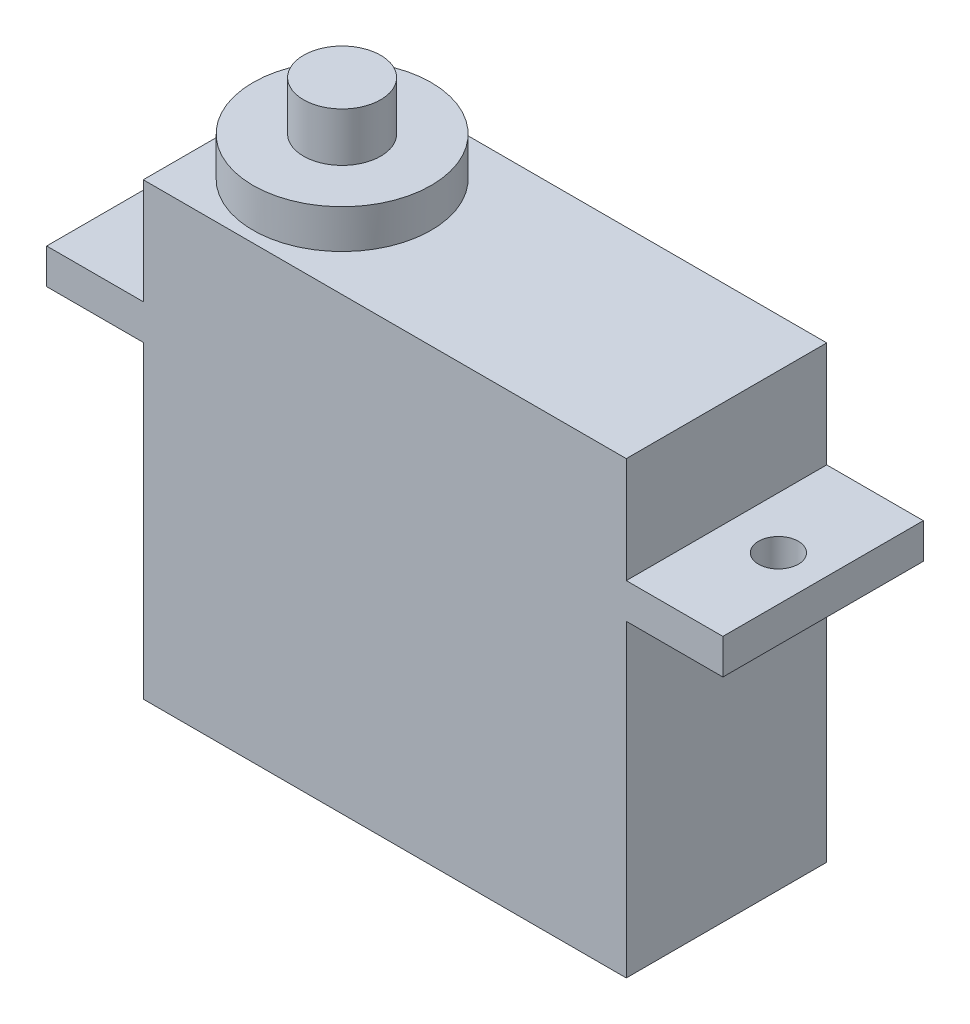
from build123d import *

# Parameters (mm, degrees)
BOSS_EXTRUDE1_DEPTH = 4.98
SKETCH2_R           = 0.99
CUT_EXTRUDE1_DEPTH  = 18.1
SKETCH3_R           = 4.42938454
BOSS_EXTRUDE2_DEPTH = 1.93
SKETCH4_R           = 1.916429151
BOSS_EXTRUDE3_DEPTH = 2.43


with BuildPart() as part:
    # Sketch1 → Boss-Extrude1 (new body, symmetric)
    with BuildSketch(Plane.XY):
        Polygon((19.1, 1.75), (23.9, 1.75), (23.9, 0), (19.1, 0), (19.1, -15.35), (-4.9, -15.35), (-4.9, 0), (-9.7, 0), (-9.7, 1.75), (-4.9, 1.75), (-4.9, 7), (19.1, 7), align=None)
    extrude(amount=BOSS_EXTRUDE1_DEPTH, both=True)

    # Sketch2 → Cut-Extrude1 (cut, through all)
    with BuildSketch(Plane(origin=(0, 1.75, 0), x_dir=(1, 0, 0), z_dir=(0, 1, 0))):
        with Locations((-7.48, 0)):
            Circle(SKETCH2_R)
        with Locations((21.68, 0)):
            Circle(SKETCH2_R)
    extrude(amount=-CUT_EXTRUDE1_DEPTH, mode=Mode.SUBTRACT)

    # Sketch3 → Boss-Extrude2 (add)
    with BuildSketch(Plane(origin=(0, 7, 0), x_dir=(1, 0, 0), z_dir=(0, 1, 0))):
        Circle(SKETCH3_R)
    extrude(amount=BOSS_EXTRUDE2_DEPTH)

    # Sketch4 → Boss-Extrude3 (add)
    with BuildSketch(Plane(origin=(0, 8.93, 0), x_dir=(1, 0, 0), z_dir=(0, 1, 0))):
        Circle(SKETCH4_R)
    extrude(amount=BOSS_EXTRUDE3_DEPTH)


solid = part.part
